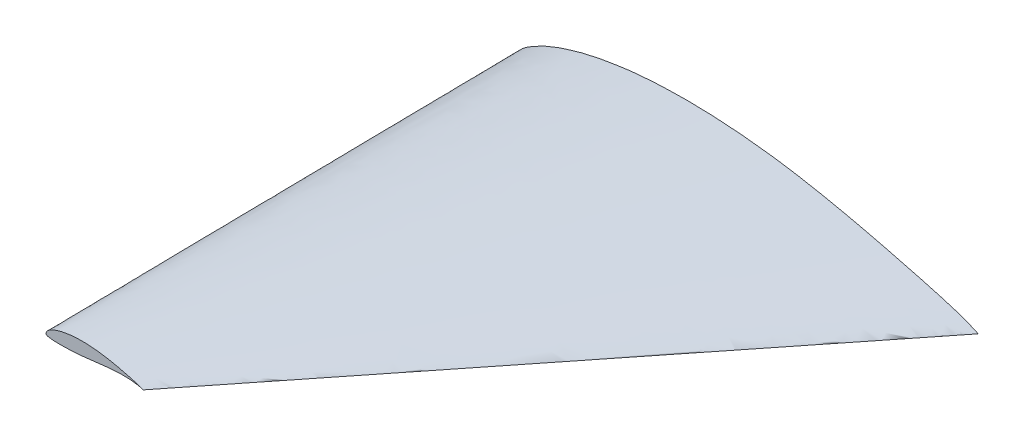
from build123d import *


with BuildPart() as part:
    # Sketch3 → Loft3 section 0
    with BuildSketch(Plane.XY.offset(609.6)):
        with BuildLine():
            add(Edge.make_bspline(
                [(127, 0), (127.008385463, 0.005841292), (126.723666865, 0.206582897), (126.406384528, 0.328668184), (125.682066076, 0.694588079), (124.761153143, 1.071623128), (123.549563855, 1.549279769), (122.091028247, 2.066766034), (120.375223664, 2.62472853), (118.418702265, 3.223239255), (116.225348748, 3.855938155), (113.809866978, 4.53746142), (111.174092463, 5.241541387), (108.341579659, 6.007114443), (105.30881797, 6.773273733), (102.106483308, 7.594724849), (98.727743031, 8.395611076), (95.211695143, 9.26079801), (91.544887389, 10.070465284), (87.775912626, 10.938023296), (83.88367825, 11.690389983), (79.922651144, 12.481095475), (75.873156688, 13.121091974), (71.786482947, 13.777670621), (67.648705571, 14.248030521), (63.507143604, 14.737561423), (59.354162387, 15.023420468), (55.227388259, 15.331270476), (51.129646559, 15.406223496), (47.088006253, 15.523764486), (43.117651981, 15.394824109), (39.228703562, 15.318892875), (35.454399305, 14.969010998), (31.782035971, 14.688521966), (28.271656778, 14.117347518), (24.877906369, 13.654767418), (21.692495547, 12.905238537), (18.631982089, 12.288100971), (15.828168063, 11.38141386), (13.150322202, 10.633317541), (10.781440664, 9.602312519), (8.525080195, 8.763148363), (6.629047063, 7.656807873), (4.881813105, 6.721692788), (3.375499525, 5.756012314), (2.181416058, 4.659707279), (1.179058544, 3.527045608), (0.553890225, 2.308634752), (0.12872203, 1.168039421), (-0.136652078, 0.254621132), (0.160882532, -0.387577318), (0.6192852, -0.774625345), (1.214806156, -1.361559673), (2.260832046, -1.592043723), (3.423969262, -2.03284824), (4.924005217, -2.136544158), (6.619209946, -2.45249634), (8.589047417, -2.508805216), (10.773052981, -2.737309293), (13.195198406, -2.748536296), (15.824930054, -2.899908854), (18.663274253, -2.855934831), (21.692038707, -2.921964916), (24.898508169, -2.803265145), (28.273252052, -2.769528916), (31.794981755, -2.570361587), (35.457949743, -2.428398934), (39.234559739, -2.134628541), (43.121574077, -1.87243392), (47.088922142, -1.477797962), (51.132359583, -1.087328359), (55.224331255, -0.616155004), (59.355321416, -0.138319305), (63.49968008, 0.39213415), (67.646291005, 0.909187371), (71.774084121, 1.419780893), (75.869638942, 1.871658452), (79.908427545, 2.314175172), (83.880835672, 2.664461948), (87.762651458, 2.99113298), (91.543704554, 3.21662207), (95.203229858, 3.400801258), (98.727958424, 3.494513971), (102.101320971, 3.529638998), (105.309502605, 3.480459397), (108.339093939, 3.358400971), (111.176476125, 3.164867119), (113.809767991, 2.920310789), (116.226882918, 2.625591537), (118.419316025, 2.301388806), (120.376526883, 1.949623214), (122.090571552, 1.575494592), (123.550810605, 1.204799951), (124.761023928, 0.829671152), (125.679369155, 0.518053223), (126.404522168, 0.233276877), (126.716465034, 0.115826887), (126.992894374, -0.004949761), (127, 0)],
                knots=[0, 0, 0, 0, 0.000652376, 0.002403448, 0.005256568, 0.009165764, 0.014096751, 0.020022012, 0.026896344, 0.034706383, 0.043414458, 0.05299002, 0.063396809, 0.074601254, 0.08653103, 0.0991543, 0.112392946, 0.126224492, 0.140544889, 0.155318673, 0.170431652, 0.185859272, 0.201486855, 0.217293377, 0.233167489, 0.2490861, 0.264958726, 0.280747987, 0.296380919, 0.311801214, 0.326956198, 0.341782747, 0.356247564, 0.370274835, 0.383861908, 0.396887692, 0.409401212, 0.421252506, 0.432540778, 0.443065253, 0.452987148, 0.462044499, 0.470525623, 0.478015714, 0.484719936, 0.490901449, 0.496493482, 0.50193463, 0.506331604, 0.510717667, 0.511954045, 0.514195842, 0.517506907, 0.521314719, 0.52610709, 0.531740963, 0.538337761, 0.545822104, 0.554208084, 0.563431264, 0.573484427, 0.584310043, 0.595866543, 0.608108297, 0.620979222, 0.634441734, 0.648424207, 0.662880137, 0.677739163, 0.692957281, 0.708452453, 0.724176515, 0.740041984, 0.755990469, 0.771938353, 0.787811294, 0.803535896, 0.819040498, 0.834255058, 0.849121195, 0.863570137, 0.877552378, 0.891006016, 0.903874255, 0.916114356, 0.927680384, 0.938530909, 0.948621564, 0.957908587, 0.966363629, 0.97395265, 0.980639895, 0.986402983, 0.99120656, 0.995011197, 0.997773026, 0.999447193, 1, 1, 1, 1], degree=3))
        make_face()
    # Sketch2 → Loft3 section 1
    with BuildSketch(Plane.XY):
        with BuildLine():
            add(Edge.make_bspline(
                [(609.6, 0), (609.64025022, 0.028038202), (608.27360095, 0.991597906), (606.750645736, 1.577607284), (603.273917166, 3.33402278), (598.853535085, 5.143791016), (593.037906504, 7.436542889), (586.036935584, 9.920476962), (577.801073588, 12.598696943), (568.409770871, 15.471548426), (557.881673991, 18.508503146), (546.287361495, 21.779814815), (533.635643822, 25.159398656), (520.039582361, 28.834149325), (505.482326254, 32.511713919), (490.111119878, 36.454679274), (473.893166546, 40.298933164), (457.016136687, 44.451830448), (439.415459466, 48.338233361), (421.324380604, 52.502511819), (402.641655599, 56.11387192), (383.628725492, 59.909258281), (364.191152104, 62.981241474), (344.575118146, 66.13281898), (324.713786741, 68.390546501), (304.834289299, 70.74029483), (284.89997946, 72.112418245), (265.091463645, 73.590098287), (245.422303484, 73.94987278), (226.022430015, 74.514069534), (206.96472951, 73.895155723), (188.2977771, 73.530685801), (170.181116666, 71.851252791), (152.553772662, 70.504905437), (135.703952536, 67.763268085), (119.413950571, 65.542883604), (104.123978624, 61.945144978), (89.433514029, 58.982884662), (75.9752067, 54.630786526), (63.121546572, 51.039924197), (51.750915187, 46.091100089), (40.920384935, 42.063112144), (31.819425901, 36.752677792), (23.432702905, 32.264125384), (16.202397719, 27.628859105), (10.47079708, 22.366594941), (5.65948101, 16.92981892), (2.658673081, 11.081446807), (0.617865742, 5.606589221), (-0.655929974, 1.222181434), (0.772236155, -1.860371124), (2.97256896, -3.718201658), (5.83106955, -6.53548643), (10.851993819, -7.64180987), (16.435052459, -9.757671552), (23.635225041, -10.255411959), (31.77220774, -11.771982431), (41.227427603, -12.042265038), (51.710654307, -13.139084609), (63.33695235, -13.192974221), (75.95966426, -13.919562498), (89.583716416, -13.708487191), (104.121785795, -14.025431596), (119.512839209, -13.455672695), (135.711609851, -13.293738795), (152.615912423, -12.337735618), (170.198158768, -11.656314885), (188.325886746, -10.246216997), (206.983555568, -8.987682815), (226.02682628, -7.09343022), (245.435325998, -5.219176123), (265.076790022, -2.957544021), (284.905542795, -0.663932666), (304.798464385, 1.882243922), (324.702196826, 4.364099382), (344.515603782, 6.814948289), (364.174266922, 8.983960569), (383.560452216, 11.108040824), (402.628011226, 12.789417349), (421.260726998, 14.357438305), (439.40978186, 15.439785937), (456.975503321, 16.323846039), (473.894200434, 16.773667059), (490.086340663, 16.942267189), (505.485612504, 16.706205108), (520.027650906, 16.120324662), (533.647085398, 15.191362173), (546.286886358, 14.017491789), (557.889038007, 12.602839379), (568.412716918, 11.04666627), (577.807329037, 9.358191426), (586.034743448, 7.562374043), (593.043890906, 5.783039767), (598.852914856, 3.982421528), (603.260971943, 2.486655471), (606.741706407, 1.119729008), (608.239032164, 0.555969058), (609.565892997, -0.023758853), (609.6, 0)],
                knots=[0, 0, 0, 0, 0.000652376, 0.002403448, 0.005256568, 0.009165764, 0.014096751, 0.020022012, 0.026896344, 0.034706383, 0.043414458, 0.05299002, 0.063396809, 0.074601254, 0.08653103, 0.0991543, 0.112392946, 0.126224492, 0.140544889, 0.155318673, 0.170431652, 0.185859272, 0.201486855, 0.217293377, 0.233167489, 0.2490861, 0.264958726, 0.280747987, 0.296380919, 0.311801214, 0.326956198, 0.341782747, 0.356247564, 0.370274835, 0.383861908, 0.396887692, 0.409401212, 0.421252506, 0.432540778, 0.443065253, 0.452987148, 0.462044499, 0.470525623, 0.478015714, 0.484719936, 0.490901449, 0.496493482, 0.50193463, 0.506331604, 0.510717667, 0.511954045, 0.514195842, 0.517506907, 0.521314719, 0.52610709, 0.531740963, 0.538337761, 0.545822104, 0.554208084, 0.563431264, 0.573484427, 0.584310043, 0.595866543, 0.608108297, 0.620979222, 0.634441734, 0.648424207, 0.662880137, 0.677739163, 0.692957281, 0.708452453, 0.724176515, 0.740041984, 0.755990469, 0.771938353, 0.787811294, 0.803535896, 0.819040498, 0.834255058, 0.849121195, 0.863570137, 0.877552378, 0.891006016, 0.903874255, 0.916114356, 0.927680384, 0.938530909, 0.948621564, 0.957908587, 0.966363629, 0.97395265, 0.980639895, 0.986402983, 0.99120656, 0.995011197, 0.997773026, 0.999447193, 1, 1, 1, 1], degree=3))
        make_face()
    loft()


solid = part.part
